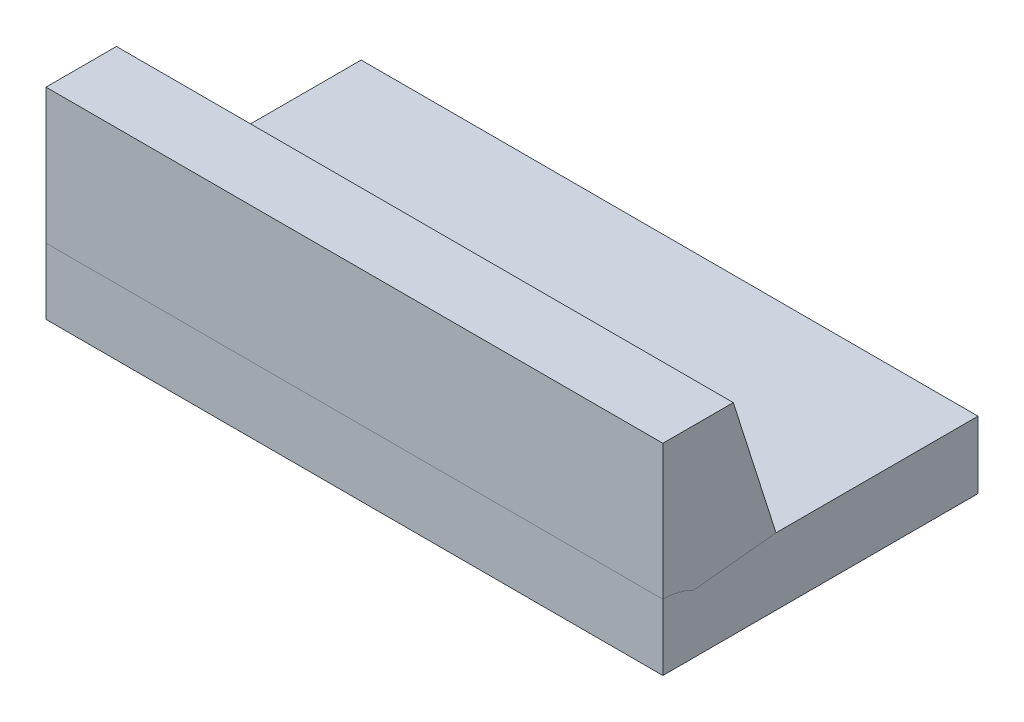
from build123d import *

# Parameters (mm, degrees)
SKETCH1_W               = 46
SKETCH1_H               = 23.5
BOSS_EXTRUDE1_DEPTH     = 5
SKETCH2_W               = 46
SKETCH2_H               = 10.437907818
BOSS_EXTRUDE2_DEPTH     = 10
SKETCH1_2_W             = 46
SKETCH1_2_H             = 23.5
BOSS_EXTRUDE3_DEPTH     = 5
CUT_EXTRUDE1_DEPTH      = 31.976218935
CUT_EXTRUDE1_DEPTH_BACK = 31.976218935
SKETCH3_R               = 2
CUT_EXTRUDE2_DEPTH      = 51.030535296
CUT_EXTRUDE2_DEPTH_BACK = 51.030535296
SKETCH4_R               = 4.930418427
CUT_EXTRUDE3_DEPTH      = 51.030535296
CUT_EXTRUDE3_DEPTH_BACK = 51.030535296


with BuildPart() as part:
    # Sketch1 → Boss-Extrude1 (new body)
    with BuildSketch(Plane(origin=(0, 0, 0), x_dir=(1, 0, 0), z_dir=(0, 1, 0))):
        with Locations((-0.926380368, 0.98006135)):
            Rectangle(SKETCH1_W, SKETCH1_H)
    extrude(amount=BOSS_EXTRUDE1_DEPTH)


with BuildPart() as body_2:
    # Sketch2 → Boss-Extrude2 (new body)
    with BuildSketch(Plane(origin=(0, 5, 0), x_dir=(1, 0, 0), z_dir=(0, 1, 0))):
        with Locations((-0.926380368, -5.550984741)):
            Rectangle(SKETCH2_W, SKETCH2_H)
    extrude(amount=BOSS_EXTRUDE2_DEPTH)

    # Sketch1_2 → Boss-Extrude3 (add)
    with BuildSketch(Plane(origin=(0, 0, 0), x_dir=(1, 0, 0), z_dir=(0, 1, 0))):
        with Locations((-0.926380368, 0.98006135)):
            Rectangle(SKETCH1_2_W, SKETCH1_2_H)
    extrude(amount=BOSS_EXTRUDE3_DEPTH)

    # Sketch3 → Cut-Extrude1 (cut, two sides: drawn at the far end of the back side and taken through both)
    with BuildSketch(Plane.XZ.offset(-CUT_EXTRUDE1_DEPTH_BACK)):
        with Locations((17.317152834, -0.321999767)):
            Circle(SKETCH3_R)
        with Locations((-11.807442733, -0.541888977)):
            Circle(SKETCH3_R)
    extrude(amount=CUT_EXTRUDE1_DEPTH + CUT_EXTRUDE1_DEPTH_BACK, mode=Mode.SUBTRACT)

    # Sketch4 → Cut-Extrude2 (cut, two sides: drawn at the far end of the back side and taken through both)
    with BuildSketch(Plane(origin=(22.073619632, 0, 0), x_dir=(0, 0, -1), z_dir=(1, 0, 0)).offset(-CUT_EXTRUDE2_DEPTH_BACK)):
        with Locations((-10.76993865, 0)):
            Circle(SKETCH4_R)
    extrude(amount=CUT_EXTRUDE2_DEPTH + CUT_EXTRUDE2_DEPTH_BACK, mode=Mode.SUBTRACT)

    # Sketch5 → Cut-Extrude3 (cut, two sides: drawn at the far end of the back side and taken through both)
    with BuildSketch(Plane(origin=(22.073619632, 0, 0), x_dir=(0, 0, -1), z_dir=(1, 0, 0)).offset(-CUT_EXTRUDE3_DEPTH_BACK)):
        Polygon((-0.332030832, 5), (-2.332030832, 5), (-5.517358605, 15), (-0.332030832, 15), align=None)
    extrude(amount=CUT_EXTRUDE3_DEPTH + CUT_EXTRUDE3_DEPTH_BACK, mode=Mode.SUBTRACT)


solid = Compound([part.part, body_2.part])
